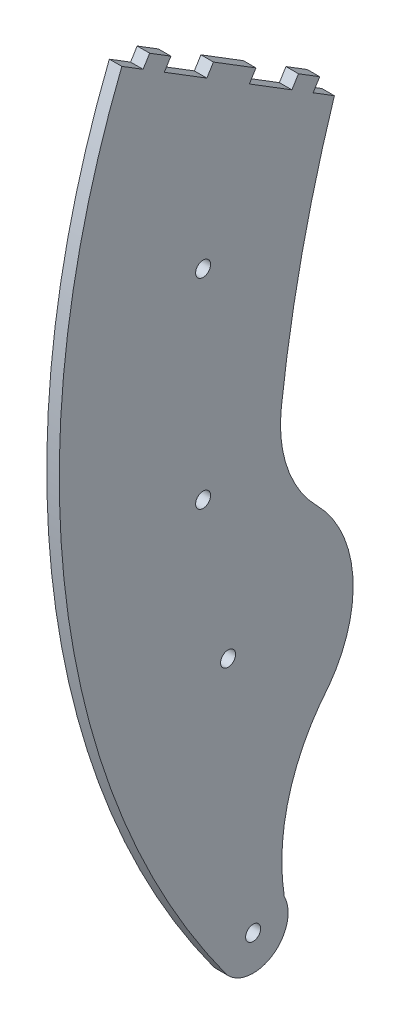
from build123d import *

# Parameters (mm, degrees)
CROQUIS1_R              = 1.5
SALIENTE_EXTRUIR1_DEPTH = 2.5


with BuildPart() as part:
    # Croquis1 → Saliente-Extruir1 (new body)
    with BuildSketch(Plane(origin=(0, 0, 0), x_dir=(0, 0, -1), z_dir=(1, 0, 0))):
        with BuildLine():
            Line((21.251917537, 86.83352739), (17.00153403, 89.466821912))
            Line((17.00153403, 89.466821912), (18.318181291, 91.592013666))
            Line((18.318181291, 91.592013666), (14.067797783, 94.225308188))
            Line((14.067797783, 94.225308188), (12.751150522, 92.100116434))
            Line((12.751150522, 92.100116434), (4.250383507, 97.366705478))
            Line((4.250383507, 97.366705478), (5.567030768, 99.491897232))
            Line((5.567030768, 99.491897232), (-2.933736246, 104.758486276))
            Line((-2.933736246, 104.758486276), (-4.250383507, 102.633294522))
            Line((-4.250383507, 102.633294522), (-12.751150522, 107.899883566))
            Line((-12.751150522, 107.899883566), (-11.434503261, 110.02507532))
            Line((-11.434503261, 110.02507532), (-15.684886769, 112.658369842))
            Line((-15.684886769, 112.658369842), (-17.00153403, 110.533178088))
            Line((-17.00153403, 110.533178088), (-21.251917537, 113.16647261))
            ThreePointArc((-21.251917537, 113.16647261), (-32.419507908, 26.647274601), (-0.370758332, -54.489427017))
            ThreePointArc((-0.370758332, -54.489427017), (8.867523579, -55.834574652), (11.226722216, -46.801886424))
            ThreePointArc((11.226722216, -46.801886424), (12.220238585, -29.769593029), (20.221051617, -14.700648676))
            ThreePointArc((20.221051617, -14.700648676), (24.926355942, 1.917493015), (17.734708518, 17.620445902))
            ThreePointArc((17.734708518, 17.620445902), (11.831680909, 27.101025049), (10.645879945, 38.206023562))
            ThreePointArc((10.645879945, 38.206023562), (14.782652045, 62.774142971), (21.251917537, 86.83352739))
        make_face()
        with Locations((5, -50)):
            Circle(CROQUIS1_R, mode=Mode.SUBTRACT)
        Circle(CROQUIS1_R, mode=Mode.SUBTRACT)
        with Locations((-5, 30)):
            Circle(CROQUIS1_R, mode=Mode.SUBTRACT)
        with Locations((-5, 70)):
            Circle(CROQUIS1_R, mode=Mode.SUBTRACT)
    extrude(amount=SALIENTE_EXTRUIR1_DEPTH)


solid = part.part
